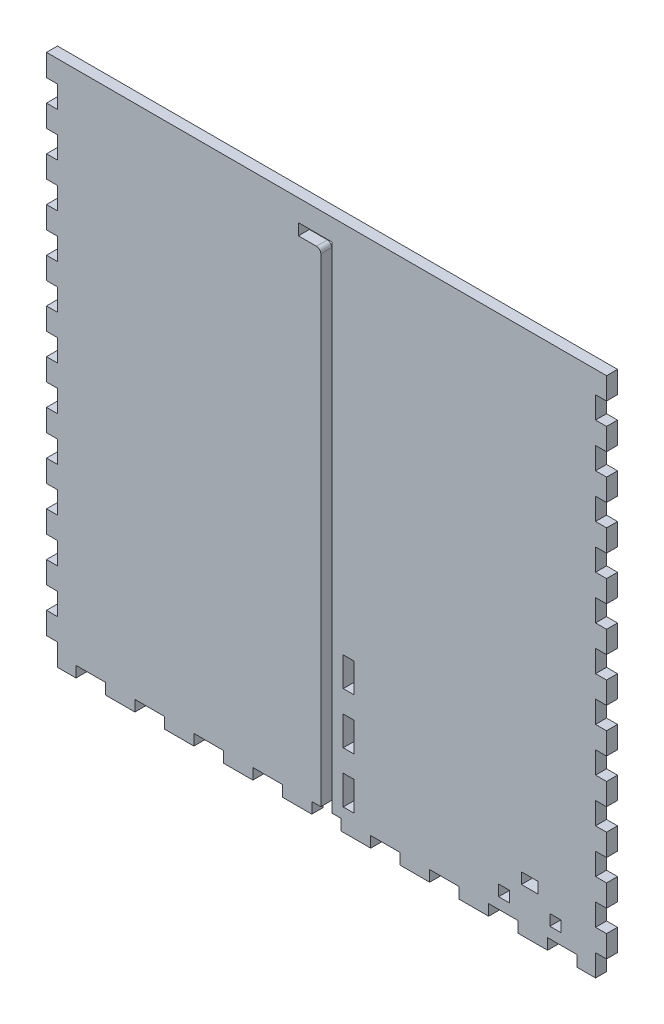
from build123d import *

# Parameters (mm, degrees)
SKETCH1_W              = 323.85
SKETCH1_H              = 139.7
BOSS_EXTRUDE1_DEPTH    = 6.35
SKETCH2_W              = 323.85
SKETCH2_H              = 139.7
SKETCH2_W_2            = 311.15
SKETCH2_H_2            = 127
BOSS_EXTRUDE2_DEPTH    = 298.45
SKETCH3_W              = 6.35
SKETCH3_H              = 16.933333333
SKETCH3_H_2            = 16.933333334
DOOR_SLOT_DEPTH        = 12.7
SKETCH4_W              = 6.35
SKETCH4_H              = 15.875
DOOR_GUIDE_HOLES_DEPTH = 6.35
LEVER_HOLES_W          = 9.652
LEVER_HOLES_H          = 6.35
LEVER_HOLES_W_2        = 6.35
CUT_EXTRUDE1_DEPTH     = 140.7
CUT_EXTRUDE2_REACH     = 325.85
SKETCH7_R              = 26.9875
CUT_EXTRUDE3_REACH     = 325.85
SKETCH8_R              = 3.175
SKETCH15_W             = 133.35
SKETCH15_H             = 338.76825338
CUT_EXTRUDE8_DEPTH     = 324.85
FRONT_BACK_W           = 6.35
FRONT_BACK_H           = 12.7
FRONT_BACK_W_2         = 17.044736842
FRONT_BACK_H_2         = 6.35
CUT_EXTRUDE9_DEPTH     = 7.35


with BuildPart() as part:
    # Sketch1 → Boss-Extrude1 (new body)
    with BuildSketch(Plane(origin=(0, 0, 0), x_dir=(1, 0, 0), z_dir=(0, 1, 0))):
        Rectangle(SKETCH1_W, SKETCH1_H)
    extrude(amount=BOSS_EXTRUDE1_DEPTH)

    # Sketch2 → Boss-Extrude2 (add)
    with BuildSketch(Plane(origin=(0, 6.35, 0), x_dir=(1, 0, 0), z_dir=(0, 1, 0))):
        Rectangle(SKETCH2_W, SKETCH2_H)
        Rectangle(SKETCH2_W_2, SKETCH2_H_2, mode=Mode.SUBTRACT)
    extrude(amount=BOSS_EXTRUDE2_DEPTH)

    # Sketch3 → Door Slot (cut)
    with BuildSketch(Plane.XY.offset(69.85)):
        with BuildLine():
            Line((-3.302, 283.21), (-3.302, 6.35))
            Line((-3.302, 6.35), (3.302, 6.35))
            Line((3.302, 6.35), (3.302, 292.354))
            Line((3.302, 292.354), (-16.256, 292.354))
            Line((-16.256, 292.354), (-16.256, 285.75))
            Line((-16.256, 285.75), (-5.842, 285.75))
            ThreePointArc((-5.842, 285.75), (-4.045948776, 285.006051224), (-3.302, 283.21))
        make_face()
        with Locations((12.827, 80.433333334)):
            Rectangle(SKETCH3_W, SKETCH3_H)
        with Locations((12.827, 50.8)):
            Rectangle(SKETCH3_W, SKETCH3_H_2)
        with Locations((12.827, 21.166666667)):
            Rectangle(SKETCH3_W, SKETCH3_H)
    extrude(amount=-DOOR_SLOT_DEPTH, mode=Mode.SUBTRACT)

    # Sketch4 → Door Guide Holes (cut)
    with BuildSketch(Plane.XY.offset(-63.5)):
        with Locations((-19.431, 284.1625)):
            Rectangle(SKETCH4_W, SKETCH4_H)
        with Locations((-19.431, 255.5875)):
            Rectangle(SKETCH4_W, SKETCH4_H)
        with Locations((-19.431, 227.0125)):
            Rectangle(SKETCH4_W, SKETCH4_H)
        with Locations((-19.431, 198.4375)):
            Rectangle(SKETCH4_W, SKETCH4_H)
        with Locations((-19.431, 169.8625)):
            Rectangle(SKETCH4_W, SKETCH4_H)
        with Locations((-19.431, 141.2875)):
            Rectangle(SKETCH4_W, SKETCH4_H)
        with Locations((-19.431, 112.7125)):
            Rectangle(SKETCH4_W, SKETCH4_H)
        with Locations((-19.431, 84.1375)):
            Rectangle(SKETCH4_W, SKETCH4_H)
        with Locations((-19.431, 55.5625)):
            Rectangle(SKETCH4_W, SKETCH4_H)
        with Locations((-19.431, 26.9875)):
            Rectangle(SKETCH4_W, SKETCH4_H)
    door_guide_holes = extrude(amount=-DOOR_GUIDE_HOLES_DEPTH, mode=Mode.SUBTRACT)

    # Mirror1: Door Guide Holes across plane
    add(door_guide_holes.mirror(Plane.ZY.offset(6.477)), mode=Mode.SUBTRACT)

    # Lever Holes → Cut-Extrude1 (cut, through all)
    with BuildSketch(Plane.XY.offset(69.85)):
        with Locations((117.5385, 28.575)):
            Rectangle(LEVER_HOLES_W, LEVER_HOLES_H)
        with Locations((102.743, 15.875)):
            Rectangle(LEVER_HOLES_W_2, LEVER_HOLES_H)
        with Locations((132.334, 15.875)):
            Rectangle(LEVER_HOLES_W_2, LEVER_HOLES_H)
    extrude(amount=-CUT_EXTRUDE1_DEPTH, mode=Mode.SUBTRACT)

    # Sketch7 → Cut-Extrude2 (cut, up to next)
    with BuildSketch(Plane(origin=(161.925, 0, 0), x_dir=(0, 0, -1), z_dir=(1, 0, 0)), mode=Mode.PRIVATE) as cut_extrude2_sk1:
        with Locations((0, 55.372)):
            Circle(SKETCH7_R)
    cut_extrude2_tool1 = extrude(cut_extrude2_sk1.sketch, amount=-CUT_EXTRUDE2_REACH, mode=Mode.PRIVATE) & part.part
    add(cut_extrude2_tool1.solids().sort_by_distance((161.925, 55.372, 0))[0], mode=Mode.SUBTRACT)
    # Sketch7 → Cut-Extrude2 (cut, up to next)
    with BuildSketch(Plane(origin=(161.925, 0, 0), x_dir=(0, 0, -1), z_dir=(1, 0, 0)), mode=Mode.PRIVATE) as cut_extrude2_sk2:
        with BuildLine():
            Line((-37.211, 89.408), (-37.211, 92.583))
            Line((-37.211, 92.583), (-34.036, 92.583))
            ThreePointArc((-34.036, 92.583), (-39.45606403, 94.82806403), (-37.211, 89.408))
        make_face()
    cut_extrude2_tool2 = extrude(cut_extrude2_sk2.sketch, amount=-CUT_EXTRUDE2_REACH, mode=Mode.PRIVATE) & part.part
    add(cut_extrude2_tool2.solids().sort_by_distance((161.925, 93.032171, 37.660171))[0], mode=Mode.SUBTRACT)
    # Sketch7 → Cut-Extrude2 (cut, up to next)
    with BuildSketch(Plane(origin=(161.925, 0, 0), x_dir=(0, 0, -1), z_dir=(1, 0, 0)), mode=Mode.PRIVATE) as cut_extrude2_sk3:
        with BuildLine():
            Line((-34.036, 92.583), (-37.211, 92.583))
            Line((-37.211, 92.583), (-37.211, 89.408))
            ThreePointArc((-37.211, 89.408), (-34.96593597, 90.33793597), (-34.036, 92.583))
        make_face()
    cut_extrude2_tool3 = extrude(cut_extrude2_sk3.sketch, amount=-CUT_EXTRUDE2_REACH, mode=Mode.PRIVATE) & part.part
    add(cut_extrude2_tool3.solids().sort_by_distance((161.925, 91.235488, 35.863488))[0], mode=Mode.SUBTRACT)
    # Sketch7 → Cut-Extrude2 (cut, up to next)
    with BuildSketch(Plane(origin=(161.925, 0, 0), x_dir=(0, 0, -1), z_dir=(1, 0, 0)), mode=Mode.PRIVATE) as cut_extrude2_sk4:
        with BuildLine():
            Line((-37.211, 89.408), (-37.211, 92.583))
            Line((-37.211, 92.583), (-34.036, 92.583))
            ThreePointArc((-34.036, 92.583), (-39.45606403, 94.82806403), (-37.211, 89.408))
        make_face()
    cut_extrude2_tool4 = extrude(cut_extrude2_sk4.sketch, amount=-CUT_EXTRUDE2_REACH, mode=Mode.PRIVATE) & part.part
    add(cut_extrude2_tool4.solids().sort_by_distance((161.925, 93.032171, 37.660171))[0], mode=Mode.SUBTRACT)
    # Sketch7 → Cut-Extrude2 (cut, up to next)
    with BuildSketch(Plane(origin=(161.925, 0, 0), x_dir=(0, 0, -1), z_dir=(1, 0, 0)), mode=Mode.PRIVATE) as cut_extrude2_sk5:
        with BuildLine():
            Line((-34.036, 92.583), (-37.211, 92.583))
            Line((-37.211, 92.583), (-37.211, 89.408))
            ThreePointArc((-37.211, 89.408), (-34.96593597, 90.33793597), (-34.036, 92.583))
        make_face()
    cut_extrude2_tool5 = extrude(cut_extrude2_sk5.sketch, amount=-CUT_EXTRUDE2_REACH, mode=Mode.PRIVATE) & part.part
    add(cut_extrude2_tool5.solids().sort_by_distance((161.925, 91.235488, 35.863488))[0], mode=Mode.SUBTRACT)
    # Sketch7 → Cut-Extrude2 (cut, up to next)
    with BuildSketch(Plane(origin=(161.925, 0, 0), x_dir=(0, 0, -1), z_dir=(1, 0, 0)), mode=Mode.PRIVATE) as cut_extrude2_sk6:
        with BuildLine():
            ThreePointArc((40.386, 92.583), (37.211, 95.758), (34.036, 92.583))
            Line((34.036, 92.583), (37.211, 92.583))
            Line((37.211, 92.583), (37.211, 89.408))
            ThreePointArc((37.211, 89.408), (39.45606403, 90.33793597), (40.386, 92.583))
        make_face()
    cut_extrude2_tool6 = extrude(cut_extrude2_sk6.sketch, amount=-CUT_EXTRUDE2_REACH, mode=Mode.PRIVATE) & part.part
    add(cut_extrude2_tool6.solids().sort_by_distance((161.925, 93.032171, -37.660171))[0], mode=Mode.SUBTRACT)
    # Sketch7 → Cut-Extrude2 (cut, up to next)
    with BuildSketch(Plane(origin=(161.925, 0, 0), x_dir=(0, 0, -1), z_dir=(1, 0, 0)), mode=Mode.PRIVATE) as cut_extrude2_sk7:
        with BuildLine():
            Line((37.211, 92.583), (34.036, 92.583))
            ThreePointArc((34.036, 92.583), (34.96593597, 90.33793597), (37.211, 89.408))
            Line((37.211, 89.408), (37.211, 92.583))
        make_face()
    cut_extrude2_tool7 = extrude(cut_extrude2_sk7.sketch, amount=-CUT_EXTRUDE2_REACH, mode=Mode.PRIVATE) & part.part
    add(cut_extrude2_tool7.solids().sort_by_distance((161.925, 91.235488, -35.863488))[0], mode=Mode.SUBTRACT)
    # Sketch7 → Cut-Extrude2 (cut, up to next)
    with BuildSketch(Plane(origin=(161.925, 0, 0), x_dir=(0, 0, -1), z_dir=(1, 0, 0)), mode=Mode.PRIVATE) as cut_extrude2_sk8:
        with BuildLine():
            ThreePointArc((40.386, 92.583), (37.211, 95.758), (34.036, 92.583))
            Line((34.036, 92.583), (37.211, 92.583))
            Line((37.211, 92.583), (37.211, 89.408))
            ThreePointArc((37.211, 89.408), (39.45606403, 90.33793597), (40.386, 92.583))
        make_face()
    cut_extrude2_tool8 = extrude(cut_extrude2_sk8.sketch, amount=-CUT_EXTRUDE2_REACH, mode=Mode.PRIVATE) & part.part
    add(cut_extrude2_tool8.solids().sort_by_distance((161.925, 93.032171, -37.660171))[0], mode=Mode.SUBTRACT)
    # Sketch7 → Cut-Extrude2 (cut, up to next)
    with BuildSketch(Plane(origin=(161.925, 0, 0), x_dir=(0, 0, -1), z_dir=(1, 0, 0)), mode=Mode.PRIVATE) as cut_extrude2_sk9:
        with BuildLine():
            Line((37.211, 92.583), (34.036, 92.583))
            ThreePointArc((34.036, 92.583), (34.96593597, 90.33793597), (37.211, 89.408))
            Line((37.211, 89.408), (37.211, 92.583))
        make_face()
    cut_extrude2_tool9 = extrude(cut_extrude2_sk9.sketch, amount=-CUT_EXTRUDE2_REACH, mode=Mode.PRIVATE) & part.part
    add(cut_extrude2_tool9.solids().sort_by_distance((161.925, 91.235488, -35.863488))[0], mode=Mode.SUBTRACT)
    # Sketch7 → Cut-Extrude2 (cut, up to next)
    with BuildSketch(Plane(origin=(161.925, 0, 0), x_dir=(0, 0, -1), z_dir=(1, 0, 0)), mode=Mode.PRIVATE) as cut_extrude2_sk10:
        with BuildLine():
            ThreePointArc((-34.036, 18.161), (-34.96593597, 20.40606403), (-37.211, 21.336))
            Line((-37.211, 21.336), (-37.211, 18.161))
            Line((-37.211, 18.161), (-34.036, 18.161))
        make_face()
    cut_extrude2_tool10 = extrude(cut_extrude2_sk10.sketch, amount=-CUT_EXTRUDE2_REACH, mode=Mode.PRIVATE) & part.part
    add(cut_extrude2_tool10.solids().sort_by_distance((161.925, 19.508512, 35.863488))[0], mode=Mode.SUBTRACT)
    # Sketch7 → Cut-Extrude2 (cut, up to next)
    with BuildSketch(Plane(origin=(161.925, 0, 0), x_dir=(0, 0, -1), z_dir=(1, 0, 0)), mode=Mode.PRIVATE) as cut_extrude2_sk11:
        with BuildLine():
            Line((-37.211, 18.161), (-37.211, 21.336))
            ThreePointArc((-37.211, 21.336), (-39.45606403, 15.91593597), (-34.036, 18.161))
            Line((-34.036, 18.161), (-37.211, 18.161))
        make_face()
    cut_extrude2_tool11 = extrude(cut_extrude2_sk11.sketch, amount=-CUT_EXTRUDE2_REACH, mode=Mode.PRIVATE) & part.part
    add(cut_extrude2_tool11.solids().sort_by_distance((161.925, 17.711829, 37.660171))[0], mode=Mode.SUBTRACT)
    # Sketch7 → Cut-Extrude2 (cut, up to next)
    with BuildSketch(Plane(origin=(161.925, 0, 0), x_dir=(0, 0, -1), z_dir=(1, 0, 0)), mode=Mode.PRIVATE) as cut_extrude2_sk12:
        with BuildLine():
            ThreePointArc((-34.036, 18.161), (-34.96593597, 20.40606403), (-37.211, 21.336))
            Line((-37.211, 21.336), (-37.211, 18.161))
            Line((-37.211, 18.161), (-34.036, 18.161))
        make_face()
    cut_extrude2_tool12 = extrude(cut_extrude2_sk12.sketch, amount=-CUT_EXTRUDE2_REACH, mode=Mode.PRIVATE) & part.part
    add(cut_extrude2_tool12.solids().sort_by_distance((161.925, 19.508512, 35.863488))[0], mode=Mode.SUBTRACT)
    # Sketch7 → Cut-Extrude2 (cut, up to next)
    with BuildSketch(Plane(origin=(161.925, 0, 0), x_dir=(0, 0, -1), z_dir=(1, 0, 0)), mode=Mode.PRIVATE) as cut_extrude2_sk13:
        with BuildLine():
            Line((-37.211, 18.161), (-37.211, 21.336))
            ThreePointArc((-37.211, 21.336), (-39.45606403, 15.91593597), (-34.036, 18.161))
            Line((-34.036, 18.161), (-37.211, 18.161))
        make_face()
    cut_extrude2_tool13 = extrude(cut_extrude2_sk13.sketch, amount=-CUT_EXTRUDE2_REACH, mode=Mode.PRIVATE) & part.part
    add(cut_extrude2_tool13.solids().sort_by_distance((161.925, 17.711829, 37.660171))[0], mode=Mode.SUBTRACT)
    # Sketch7 → Cut-Extrude2 (cut, up to next)
    with BuildSketch(Plane(origin=(161.925, 0, 0), x_dir=(0, 0, -1), z_dir=(1, 0, 0)), mode=Mode.PRIVATE) as cut_extrude2_sk14:
        with BuildLine():
            ThreePointArc((40.386, 18.161), (39.45606403, 20.40606403), (37.211, 21.336))
            Line((37.211, 21.336), (37.211, 18.161))
            Line((37.211, 18.161), (34.036, 18.161))
            ThreePointArc((34.036, 18.161), (37.211, 14.986), (40.386, 18.161))
        make_face()
    cut_extrude2_tool14 = extrude(cut_extrude2_sk14.sketch, amount=-CUT_EXTRUDE2_REACH, mode=Mode.PRIVATE) & part.part
    add(cut_extrude2_tool14.solids().sort_by_distance((161.925, 17.711829, -37.660171))[0], mode=Mode.SUBTRACT)
    # Sketch7 → Cut-Extrude2 (cut, up to next)
    with BuildSketch(Plane(origin=(161.925, 0, 0), x_dir=(0, 0, -1), z_dir=(1, 0, 0)), mode=Mode.PRIVATE) as cut_extrude2_sk15:
        with BuildLine():
            Line((37.211, 18.161), (37.211, 21.336))
            ThreePointArc((37.211, 21.336), (34.96593597, 20.40606403), (34.036, 18.161))
            Line((34.036, 18.161), (37.211, 18.161))
        make_face()
    cut_extrude2_tool15 = extrude(cut_extrude2_sk15.sketch, amount=-CUT_EXTRUDE2_REACH, mode=Mode.PRIVATE) & part.part
    add(cut_extrude2_tool15.solids().sort_by_distance((161.925, 19.508512, -35.863488))[0], mode=Mode.SUBTRACT)
    # Sketch7 → Cut-Extrude2 (cut, up to next)
    with BuildSketch(Plane(origin=(161.925, 0, 0), x_dir=(0, 0, -1), z_dir=(1, 0, 0)), mode=Mode.PRIVATE) as cut_extrude2_sk16:
        with BuildLine():
            ThreePointArc((40.386, 18.161), (39.45606403, 20.40606403), (37.211, 21.336))
            Line((37.211, 21.336), (37.211, 18.161))
            Line((37.211, 18.161), (34.036, 18.161))
            ThreePointArc((34.036, 18.161), (37.211, 14.986), (40.386, 18.161))
        make_face()
    cut_extrude2_tool16 = extrude(cut_extrude2_sk16.sketch, amount=-CUT_EXTRUDE2_REACH, mode=Mode.PRIVATE) & part.part
    add(cut_extrude2_tool16.solids().sort_by_distance((161.925, 17.711829, -37.660171))[0], mode=Mode.SUBTRACT)
    # Sketch7 → Cut-Extrude2 (cut, up to next)
    with BuildSketch(Plane(origin=(161.925, 0, 0), x_dir=(0, 0, -1), z_dir=(1, 0, 0)), mode=Mode.PRIVATE) as cut_extrude2_sk17:
        with BuildLine():
            Line((37.211, 18.161), (37.211, 21.336))
            ThreePointArc((37.211, 21.336), (34.96593597, 20.40606403), (34.036, 18.161))
            Line((34.036, 18.161), (37.211, 18.161))
        make_face()
    cut_extrude2_tool17 = extrude(cut_extrude2_sk17.sketch, amount=-CUT_EXTRUDE2_REACH, mode=Mode.PRIVATE) & part.part
    add(cut_extrude2_tool17.solids().sort_by_distance((161.925, 19.508512, -35.863488))[0], mode=Mode.SUBTRACT)

    # Sketch8 → Cut-Extrude3 (cut, up to next)
    with BuildSketch(Plane.ZY.offset(161.925), mode=Mode.PRIVATE) as cut_extrude3_sk1:
        with Locations((0, 19.05)):
            Circle(SKETCH8_R)
    cut_extrude3_tool1 = extrude(cut_extrude3_sk1.sketch, amount=-CUT_EXTRUDE3_REACH, mode=Mode.PRIVATE) & part.part
    add(cut_extrude3_tool1.solids().sort_by_distance((-161.925, 19.05, 0))[0], mode=Mode.SUBTRACT)

    # Sketch15 → Cut-Extrude8 (cut, through all)
    with BuildSketch(Plane.ZY.offset(161.925)):
        with Locations((-3.175, 135.41587331)):
            Rectangle(SKETCH15_W, SKETCH15_H)
    extrude(amount=-CUT_EXTRUDE8_DEPTH, mode=Mode.SUBTRACT)

    # Front/Back → Cut-Extrude9 (cut, through all)
    with BuildSketch(Plane.XY.offset(69.85)):
        with Locations((-158.75, 6.35)):
            Rectangle(FRONT_BACK_W, FRONT_BACK_H)
        with Locations((-136.357894737, 3.175)):
            Rectangle(FRONT_BACK_W_2, FRONT_BACK_H_2)
        with Locations((-158.75, 31.75)):
            Rectangle(FRONT_BACK_W, FRONT_BACK_H)
        with Locations((-102.268421053, 3.175)):
            Rectangle(FRONT_BACK_W_2, FRONT_BACK_H_2)
        with Locations((-158.75, 57.15)):
            Rectangle(FRONT_BACK_W, FRONT_BACK_H)
        with Locations((-68.178947368, 3.175)):
            Rectangle(FRONT_BACK_W_2, FRONT_BACK_H_2)
        with Locations((-158.75, 82.55)):
            Rectangle(FRONT_BACK_W, FRONT_BACK_H)
        with Locations((-34.089473684, 3.175)):
            Rectangle(FRONT_BACK_W_2, FRONT_BACK_H_2)
        with Locations((-158.75, 107.95)):
            Rectangle(FRONT_BACK_W, FRONT_BACK_H)
        with Locations((0, 3.175)):
            Rectangle(FRONT_BACK_W_2, FRONT_BACK_H_2)
        with Locations((-158.75, 133.35)):
            Rectangle(FRONT_BACK_W, FRONT_BACK_H)
        with Locations((34.089473684, 3.175)):
            Rectangle(FRONT_BACK_W_2, FRONT_BACK_H_2)
        with Locations((-158.75, 158.75)):
            Rectangle(FRONT_BACK_W, FRONT_BACK_H)
        with Locations((68.178947368, 3.175)):
            Rectangle(FRONT_BACK_W_2, FRONT_BACK_H_2)
        with Locations((-158.75, 184.15)):
            Rectangle(FRONT_BACK_W, FRONT_BACK_H)
        with Locations((102.268421053, 3.175)):
            Rectangle(FRONT_BACK_W_2, FRONT_BACK_H_2)
        with Locations((-158.75, 209.55)):
            Rectangle(FRONT_BACK_W, FRONT_BACK_H)
        with Locations((136.357894737, 3.175)):
            Rectangle(FRONT_BACK_W_2, FRONT_BACK_H_2)
        with Locations((-158.75, 234.95)):
            Rectangle(FRONT_BACK_W, FRONT_BACK_H)
        with Locations((158.75, 6.35)):
            Rectangle(FRONT_BACK_W, FRONT_BACK_H)
        with Locations((-158.75, 260.35)):
            Rectangle(FRONT_BACK_W, FRONT_BACK_H)
        with Locations((158.75, 31.75)):
            Rectangle(FRONT_BACK_W, FRONT_BACK_H)
        with Locations((-158.75, 285.75)):
            Rectangle(FRONT_BACK_W, FRONT_BACK_H)
        with Locations((158.75, 57.15)):
            Rectangle(FRONT_BACK_W, FRONT_BACK_H)
        with Locations((158.75, 82.55)):
            Rectangle(FRONT_BACK_W, FRONT_BACK_H)
        with Locations((158.75, 107.95)):
            Rectangle(FRONT_BACK_W, FRONT_BACK_H)
        with Locations((158.75, 133.35)):
            Rectangle(FRONT_BACK_W, FRONT_BACK_H)
        with Locations((158.75, 158.75)):
            Rectangle(FRONT_BACK_W, FRONT_BACK_H)
        with Locations((158.75, 184.15)):
            Rectangle(FRONT_BACK_W, FRONT_BACK_H)
        with Locations((158.75, 209.55)):
            Rectangle(FRONT_BACK_W, FRONT_BACK_H)
        with Locations((158.75, 234.95)):
            Rectangle(FRONT_BACK_W, FRONT_BACK_H)
        with Locations((158.75, 260.35)):
            Rectangle(FRONT_BACK_W, FRONT_BACK_H)
        with Locations((158.75, 285.75)):
            Rectangle(FRONT_BACK_W, FRONT_BACK_H)
    extrude(amount=-CUT_EXTRUDE9_DEPTH, mode=Mode.SUBTRACT)


solid = part.part
